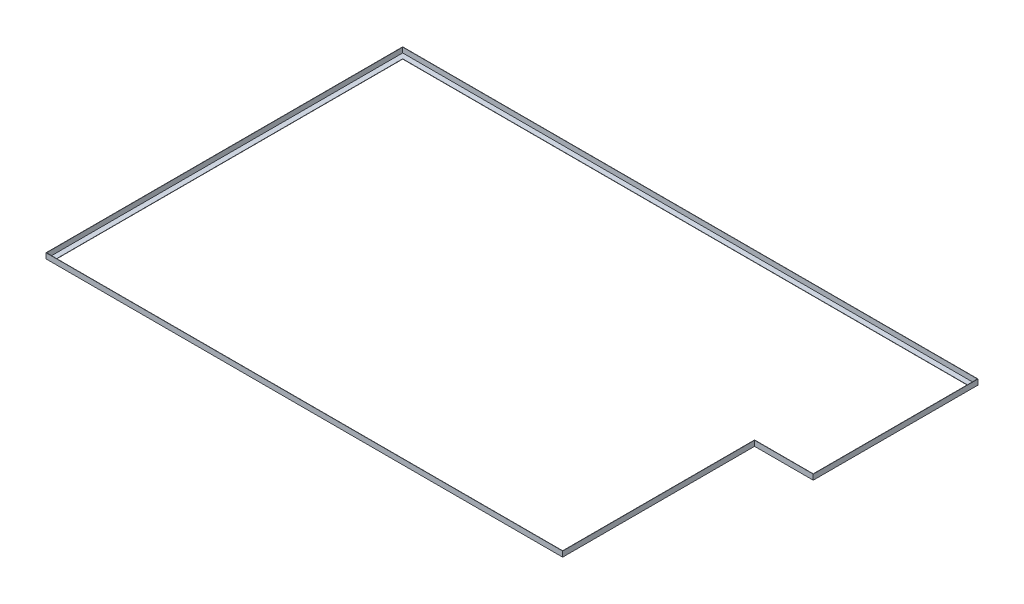
from build123d import *


with BuildPart() as part:
    # Sweep1: sweep along a path in Sketch1
    with BuildLine(Plane(origin=(0, 0, 0), x_dir=(1, 0, 0), z_dir=(0, 1, 0))) as sweep1_path:
        Line((-1459.720419904, 836.957191151), (1334.279580096, 836.957191151))
        Line((1334.279580096, 836.957191151), (1334.279580096, -1.242808849))
        Line((1334.279580096, -1.242808849), (1054.879580096, -1.242808849))
        Line((1054.879580096, -1.242808849), (1054.879580096, -915.642808849))
        Line((1054.879580096, -915.642808849), (-1459.720419904, -915.642808849))
        Line((-1459.720419904, -915.642808849), (-1459.720419904, 836.957191151))
    # Sketch2 → Sweep1 (sweep)
    with BuildSketch(Plane(origin=(0, 0, 0), x_dir=(0, 0, -1), z_dir=(1, 0, 0))):
        Polygon((-887.73, 25.4), (-887.73, 1.27), (-863.6, 1.27), (-863.6, 0), (-889, 0), (-889, 25.4), align=None)
    sweep(path=sweep1_path.line, transition=Transition.RIGHT)


solid = part.part
